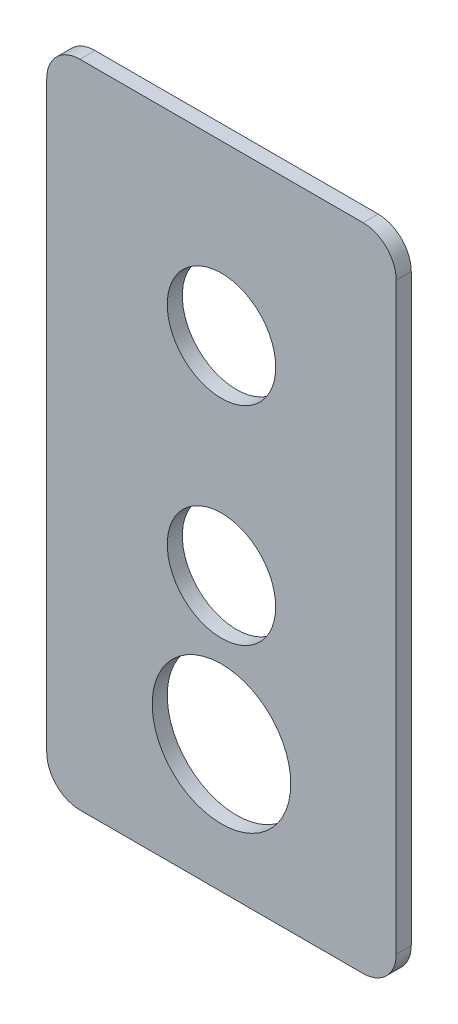
from build123d import *

# Parameters (mm, degrees)
ESBO_O1_W                = 58
ESBO_O1_H                = 2.5
RESSALTO_EXTRUS_O1_DEPTH = 107.92
FILETE1_R                = 5.5
ESBO_O2_R                = 9
CORTE_EXTRUS_O1_DEPTH    = 111.42
ESBO_O5_R                = 11.5
CORTE_EXTRUS_O2_DEPTH    = 111.42


with BuildPart() as part:
    # Esboço1 → Ressalto-extrusão1 (new body)
    with BuildSketch(Plane(origin=(0, 0, 0), x_dir=(1, 0, 0), z_dir=(0, 1, 0))):
        with Locations((22.039718439, -2.022727273)):
            Rectangle(ESBO_O1_W, ESBO_O1_H)
    extrude(amount=RESSALTO_EXTRUS_O1_DEPTH)

    # Filete1
    filete1_edges = [part.edges().sort_by_distance(p)[0] for p in [
        (51.039718439, 107.92, 2.022727273),
        (-6.960281561, 107.92, 2.022727273),
        (51.039718439, 0, 2.022727273),
        (-6.960281561, 0, 2.022727273),
    ]]
    fillet(filete1_edges, radius=FILETE1_R)

    # Esboço2 → Corte-extrusão1 (cut)
    with BuildSketch(Plane.XY.offset(3.272727273)):
        with Locations((22.039718439, 79.92)):
            Circle(ESBO_O2_R)
        with Locations((22.039718439, 45.4387)):
            Circle(ESBO_O2_R)
    extrude(amount=-CORTE_EXTRUS_O1_DEPTH, mode=Mode.SUBTRACT)

    # Esboço5 → Corte-extrusão2 (cut)
    with BuildSketch(Plane.XY.offset(3.272727273)):
        with Locations((22.039718439, 21.2424)):
            Circle(ESBO_O5_R)
    extrude(amount=-CORTE_EXTRUS_O2_DEPTH, mode=Mode.SUBTRACT)


solid = part.part
